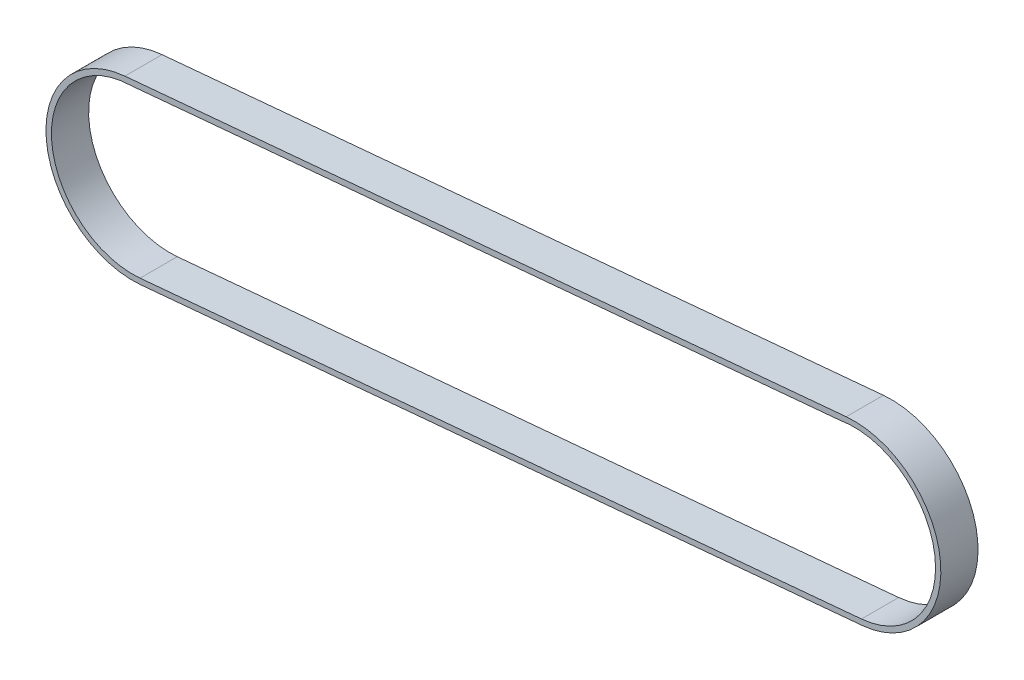
from build123d import *

# Parameters (mm, degrees)
Y_KSEKLIK_EKSTR_ZYON1_DEPTH = 7.5


with BuildPart() as part:
    # Çizim1 → Yükseklik-Ekstrüzyon1 (new body, symmetric)
    with BuildSketch(Plane(origin=(0, 0, 0), x_dir=(-1, 0, 0), z_dir=(0, 0, 1))):
        with BuildLine():
            Line((72.328772259, -16.644229091), (-218.671227741, -43.144229091))
            ThreePointArc((-218.671227741, -43.144229091), (-250.352847691, -81.174150959), (-212.322925823, -112.855770909))
            Line((-212.322925823, -112.855770909), (78.677074177, -86.355770909))
            ThreePointArc((78.677074177, -86.355770909), (110.358694128, -48.325849041), (72.328772259, -16.644229091))
        make_face()
        with BuildLine():
            ThreePointArc((-209.8089095, -110.3633999), (-248.069420133, -82.334437532), (-218.470252737, -45.27531322))
            Line((-218.470252737, -45.27531322), (72.535281972, -18.836231788))
            ThreePointArc((72.535281972, -18.836231788), (108.250828228, -49.682483602), (76.168067869, -84.291557312))
            Line((76.168067869, -84.291557312), (-209.8089095, -110.3633999))
        make_face(mode=Mode.SUBTRACT)
    extrude(amount=Y_KSEKLIK_EKSTR_ZYON1_DEPTH, both=True)


solid = part.part
